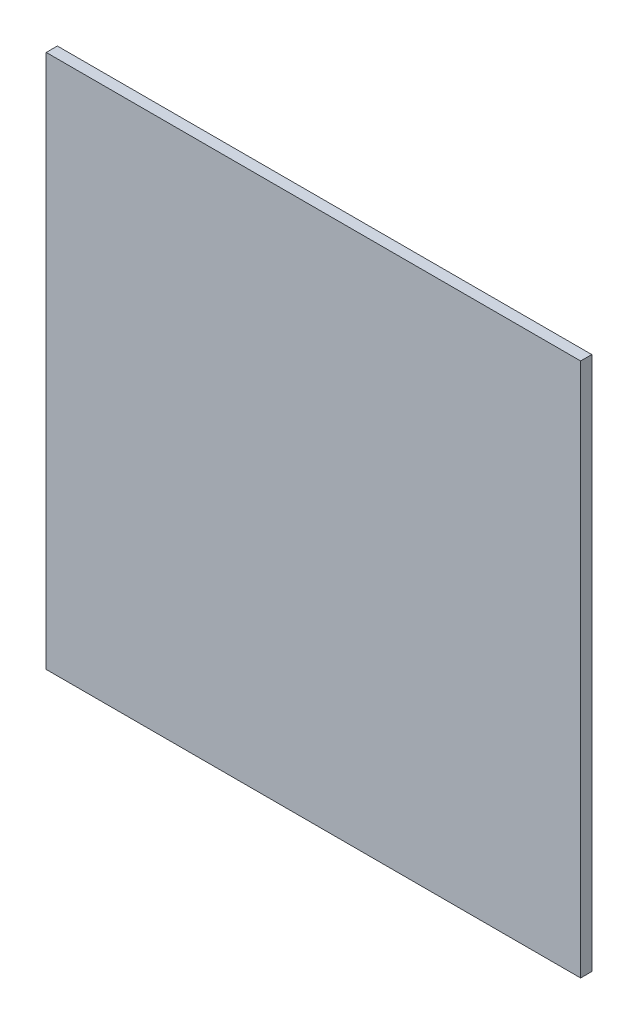
from build123d import *

# Parameters (mm, degrees)
SKETCH1_W           = 1219.2
SKETCH1_H           = 1219.2
BOSS_EXTRUDE1_DEPTH = 25.4


with BuildPart() as part:
    # Sketch1 → Boss-Extrude1 (new body)
    with BuildSketch(Plane.XY):
        with Locations((609.6, -609.6)):
            Rectangle(SKETCH1_W, SKETCH1_H)
    extrude(amount=BOSS_EXTRUDE1_DEPTH)


solid = part.part
